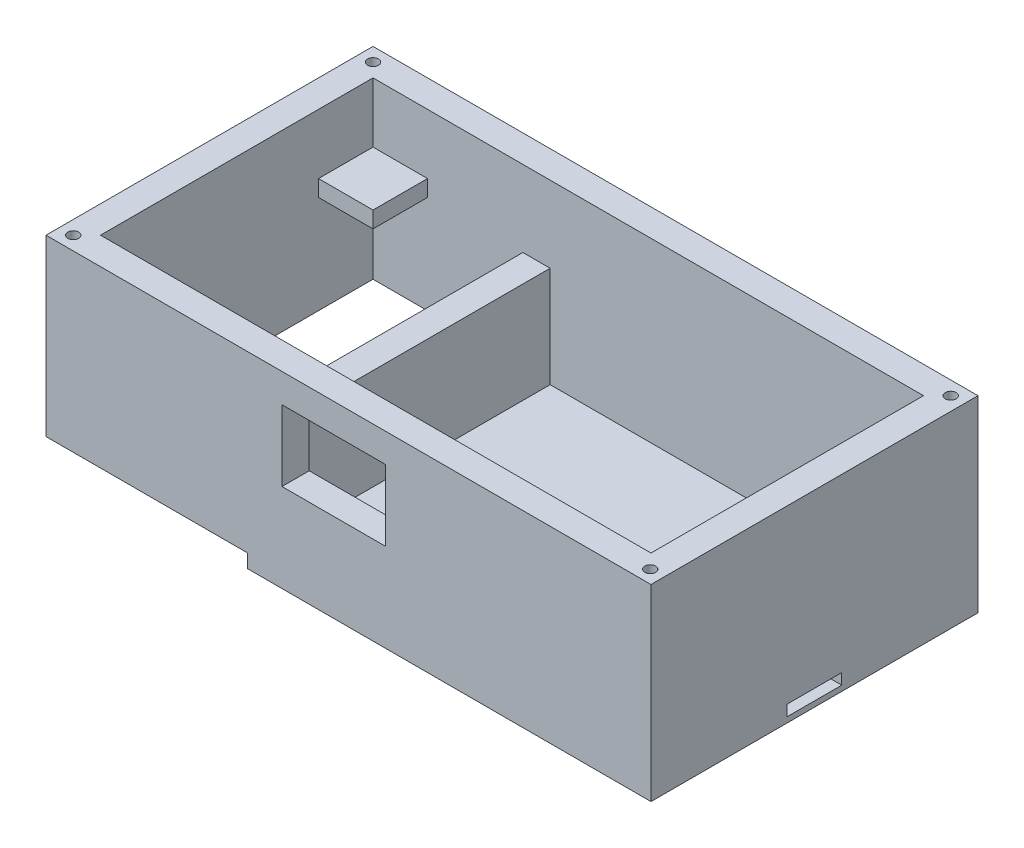
from build123d import *

# Parameters (mm, degrees)
SKETCH1_W           = 111
SKETCH1_H           = 60
BOSS_EXTRUDE1_DEPTH = 34.5
SKETCH2_W           = 101
SKETCH2_H           = 50
CUT_EXTRUDE1_DEPTH  = 11
CUT_EXTRUDE3_DEPTH  = 14
CUT_EXTRUDE5_START  = -2
SKETCH5_W           = 27.5
SKETCH5_H           = 50
SKETCH5_W_2         = 68.5
CUT_EXTRUDE5_DEPTH  = 18.5
SKETCH6_W           = 37
SKETCH6_H           = 60
CUT_EXTRUDE6_DEPTH  = 2.5
SKETCH7_R           = 1
CUT_EXTRUDE7_DEPTH  = 4
SKETCH8_R           = 1
CUT_EXTRUDE8_DEPTH  = 4
SKETCH9_W           = 19
SKETCH9_H           = 13
CUT_EXTRUDE9_DEPTH  = 10
SKETCH10_W          = 10
SKETCH10_H          = 2
CUT_EXTRUDE10_DEPTH = 70
SKETCH11_W          = 2
SKETCH11_H          = 10
CUT_EXTRUDE11_DEPTH = 2


with BuildPart() as part:
    # Sketch1 → Boss-Extrude1 (new body)
    with BuildSketch(Plane(origin=(0, 0, 0), x_dir=(1, 0, 0), z_dir=(0, 1, 0))):
        with Locations((55.5, 30)):
            Rectangle(SKETCH1_W, SKETCH1_H)
    extrude(amount=BOSS_EXTRUDE1_DEPTH)

    # Sketch2 → Cut-Extrude1 (cut)
    with BuildSketch(Plane(origin=(0, 34.5, 0), x_dir=(1, 0, 0), z_dir=(0, 1, 0))):
        with Locations((55.5, 30)):
            Rectangle(SKETCH2_W, SKETCH2_H)
    extrude(amount=-CUT_EXTRUDE1_DEPTH, mode=Mode.SUBTRACT)

    # Sketch3 → Cut-Extrude3 (cut)
    with BuildSketch(Plane(origin=(0, 34.5, 0), x_dir=(1, 0, 0), z_dir=(0, 1, 0))):
        Polygon((5, 45), (15, 45), (15, 55), (96, 55), (96, 45), (106, 45), (106, 15), (96, 15), (96, 5), (15, 5), (15, 15), (5, 15), align=None)
    extrude(amount=-CUT_EXTRUDE3_DEPTH, mode=Mode.SUBTRACT)

    # Sketch5 → Cut-Extrude5 (cut)
    with BuildSketch(Plane.XZ.offset(CUT_EXTRUDE5_START)):
        with Locations((18.75, -30)):
            Rectangle(SKETCH5_W, SKETCH5_H)
        with Locations((71.75, -30)):
            Rectangle(SKETCH5_W_2, SKETCH5_H)
    extrude(amount=-CUT_EXTRUDE5_DEPTH, mode=Mode.SUBTRACT)

    # Sketch6 → Cut-Extrude6 (cut)
    with BuildSketch(Plane.XZ):
        with Locations((18.5, -30)):
            Rectangle(SKETCH6_W, SKETCH6_H)
    extrude(amount=-CUT_EXTRUDE6_DEPTH, mode=Mode.SUBTRACT)

    # Sketch7 → Cut-Extrude7 (cut)
    with BuildSketch(Plane(origin=(0, 2.5, 0), x_dir=(-1, 0, 0), z_dir=(0, -1, 0))):
        with Locations((-2.5, 57.5)):
            Circle(SKETCH7_R)
        with Locations((-34.5, 57.5)):
            Circle(SKETCH7_R)
        with Locations((-34.5, 2.5)):
            Circle(SKETCH7_R)
        with Locations((-2.5, 2.5)):
            Circle(SKETCH7_R)
    extrude(amount=-CUT_EXTRUDE7_DEPTH, mode=Mode.SUBTRACT)

    # Sketch8 → Cut-Extrude8 (cut)
    with BuildSketch(Plane(origin=(0, 34.5, 0), x_dir=(1, 0, 0), z_dir=(0, 1, 0))):
        with Locations((2.5, 57.5)):
            Circle(SKETCH8_R)
        with Locations((108.5, 57.5)):
            Circle(SKETCH8_R)
        with Locations((108.5, 2.360383006)):
            Circle(SKETCH8_R)
        with Locations((2.5, 2.5)):
            Circle(SKETCH8_R)
    extrude(amount=-CUT_EXTRUDE8_DEPTH, mode=Mode.SUBTRACT)

    # Sketch9 → Cut-Extrude9 (cut)
    with BuildSketch(Plane.XY):
        with Locations((52.792502494, 22.713514363)):
            Rectangle(SKETCH9_W, SKETCH9_H)
    extrude(amount=-CUT_EXTRUDE9_DEPTH, mode=Mode.SUBTRACT)

    # Sketch10 → Cut-Extrude10 (cut)
    with BuildSketch(Plane(origin=(111, 0, 0), x_dir=(0, 0, -1), z_dir=(1, 0, 0))):
        with Locations((30, 2)):
            Rectangle(SKETCH10_W, SKETCH10_H)
    extrude(amount=-CUT_EXTRUDE10_DEPTH, mode=Mode.SUBTRACT)

    # Sketch11 → Cut-Extrude11 (cut, through all)
    with BuildSketch(Plane(origin=(0, 1, 0), x_dir=(1, 0, 0), z_dir=(0, 1, 0))):
        with Locations((42, 30)):
            Rectangle(SKETCH11_W, SKETCH11_H)
    extrude(amount=-CUT_EXTRUDE11_DEPTH, mode=Mode.SUBTRACT)


solid = part.part
